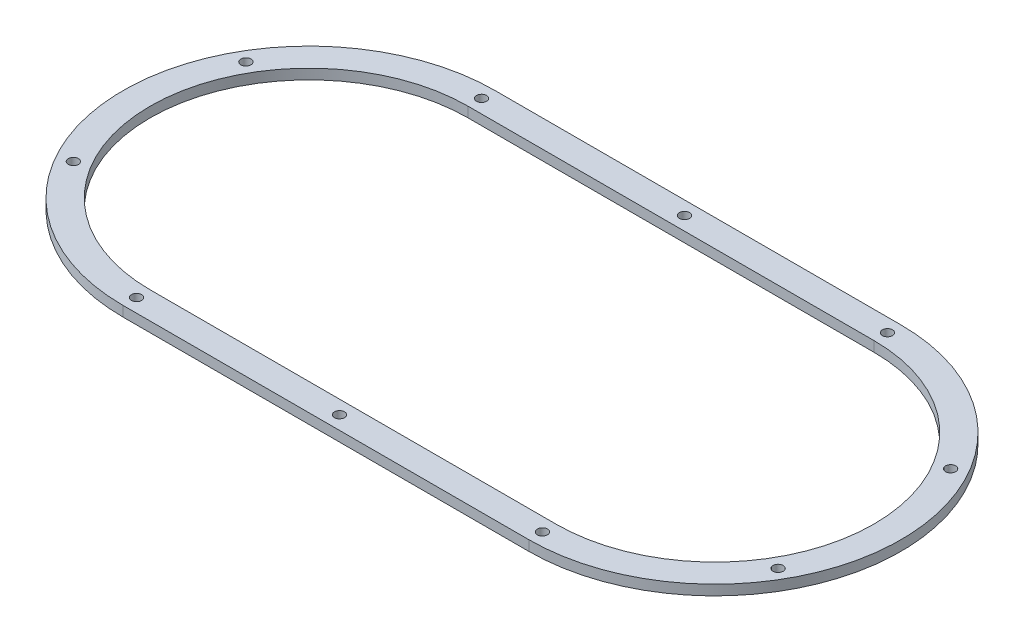
from build123d import *

# Parameters (mm, degrees)
SKETCH_1_R          = 1.5
EXTRUDE_2_DEPTH     = 3
CUT_EXTRUDE_1_DEPTH = 10
SKETCH_4_R          = 5
CUT_EXTRUDE_2_DEPTH = 10
SKETCH_5_R          = 1.5
CUT_EXTRUDE_3_DEPTH = 10
CUT_EXTRUDE_4_DEPTH = 10


with BuildPart() as part:
    # 草图1 → 凸台-拉伸2 (new body)
    with BuildSketch(Plane(origin=(0, 0, 0), x_dir=(1, 0, 0), z_dir=(0, 1, 0))):
        with BuildLine():
            Line((-60, 70), (60, 70))
            ThreePointArc((60, 70), (130, 0), (60, -70))
            Line((60, -70), (-60, -70))
            ThreePointArc((-60, -70), (-130, 0), (-60, 70))
        make_face()
        with Locations((-122, 0)):
            Circle(SKETCH_1_R, mode=Mode.SUBTRACT)
        with Locations((122, 0)):
            Circle(SKETCH_1_R, mode=Mode.SUBTRACT)
        with Locations((-30, 60)):
            Circle(SKETCH_1_R, mode=Mode.SUBTRACT)
        with Locations((30, 60)):
            Circle(SKETCH_1_R, mode=Mode.SUBTRACT)
        with Locations((30, -60)):
            Circle(SKETCH_1_R, mode=Mode.SUBTRACT)
        with Locations((-30, -60)):
            Circle(SKETCH_1_R, mode=Mode.SUBTRACT)
    extrude(amount=EXTRUDE_2_DEPTH)

    # 草图3 → 切除-拉伸1 (cut)
    with BuildSketch(Plane(origin=(0, 3, 0), x_dir=(1, 0, 0), z_dir=(0, 1, 0))):
        with BuildLine():
            Line((-60, -70), (60, -70))
            ThreePointArc((60, -70), (130, 0), (60, 70))
            Line((60, 70), (-60, 70))
            ThreePointArc((-60, 70), (-130, 0), (-60, -70))
        make_face()
        with BuildLine():
            Line((-60, -55), (60, -55))
            ThreePointArc((60, -55), (115, 0), (60, 55))
            Line((60, 55), (-60, 55))
            ThreePointArc((-60, 55), (-115, 0), (-60, -55))
        make_face(mode=Mode.SUBTRACT)
    extrude(amount=-CUT_EXTRUDE_1_DEPTH, mode=Mode.SUBTRACT)

    # 草图4 → 切除-拉伸2 (cut)
    with BuildSketch(Plane(origin=(0, 3, 0), x_dir=(1, 0, 0), z_dir=(0, 1, 0))):
        with Locations((-60, 35)):
            Circle(SKETCH_4_R)
        with Locations((-60, -35)):
            Circle(SKETCH_4_R)
        with Locations((-80.57248383, -28.315594803)):
            Circle(SKETCH_4_R)
        with Locations((-93.28697807, -10.815594803)):
            Circle(SKETCH_4_R)
        with Locations((-93.28697807, 10.815594803)):
            Circle(SKETCH_4_R)
        with Locations((-80.57248383, 28.315594803)):
            Circle(SKETCH_4_R)
        with Locations((-40, 35)):
            Circle(SKETCH_4_R)
        with Locations((-20, 35)):
            Circle(SKETCH_4_R)
        with Locations((0, 35)):
            Circle(SKETCH_4_R)
        with Locations((20, 35)):
            Circle(SKETCH_4_R)
        with Locations((40, 35)):
            Circle(SKETCH_4_R)
        with Locations((60, 35)):
            Circle(SKETCH_4_R)
        with Locations((60, -35)):
            Circle(SKETCH_4_R)
        with Locations((40, -35)):
            Circle(SKETCH_4_R)
        with Locations((20, -35)):
            Circle(SKETCH_4_R)
        with Locations((0, -35)):
            Circle(SKETCH_4_R)
        with Locations((-20, -35)):
            Circle(SKETCH_4_R)
        with Locations((-40, -35)):
            Circle(SKETCH_4_R)
        with Locations((80.57248383, 28.315594803)):
            Circle(SKETCH_4_R)
        with Locations((93.28697807, 10.815594803)):
            Circle(SKETCH_4_R)
        with Locations((93.28697807, -10.815594803)):
            Circle(SKETCH_4_R)
        with Locations((80.57248383, -28.315594803)):
            Circle(SKETCH_4_R)
    extrude(amount=-CUT_EXTRUDE_2_DEPTH, mode=Mode.SUBTRACT)

    # 草图5 → 切除-拉伸3 (cut)
    with BuildSketch(Plane(origin=(0, 3, 0), x_dir=(1, 0, 0), z_dir=(0, 1, 0))):
        with Locations((60, 51)):
            Circle(SKETCH_5_R)
        with Locations((104.167295593, 25.5)):
            Circle(SKETCH_5_R)
        with Locations((104.167295593, -25.5)):
            Circle(SKETCH_5_R)
        with Locations((60, -51)):
            Circle(SKETCH_5_R)
        with Locations((0, -51)):
            Circle(SKETCH_5_R)
        with Locations((-60, -51)):
            Circle(SKETCH_5_R)
        with Locations((-104.167295593, -25.5)):
            Circle(SKETCH_5_R)
        with Locations((-104.167295593, 25.5)):
            Circle(SKETCH_5_R)
        with Locations((-60, 51)):
            Circle(SKETCH_5_R)
        with Locations((0, 51)):
            Circle(SKETCH_5_R)
    extrude(amount=-CUT_EXTRUDE_3_DEPTH, mode=Mode.SUBTRACT)

    # 草图6 → 切除-拉伸4 (cut)
    with BuildSketch(Plane(origin=(0, 3, 0), x_dir=(1, 0, 0), z_dir=(0, 1, 0))):
        with BuildLine():
            Line((60, 47), (-60, 47))
            ThreePointArc((-60, 47), (-107, 0), (-60, -47))
            Line((-60, -47), (60, -47))
            ThreePointArc((60, -47), (107, 0), (60, 47))
        make_face()
    extrude(amount=-CUT_EXTRUDE_4_DEPTH, mode=Mode.SUBTRACT)


solid = part.part
